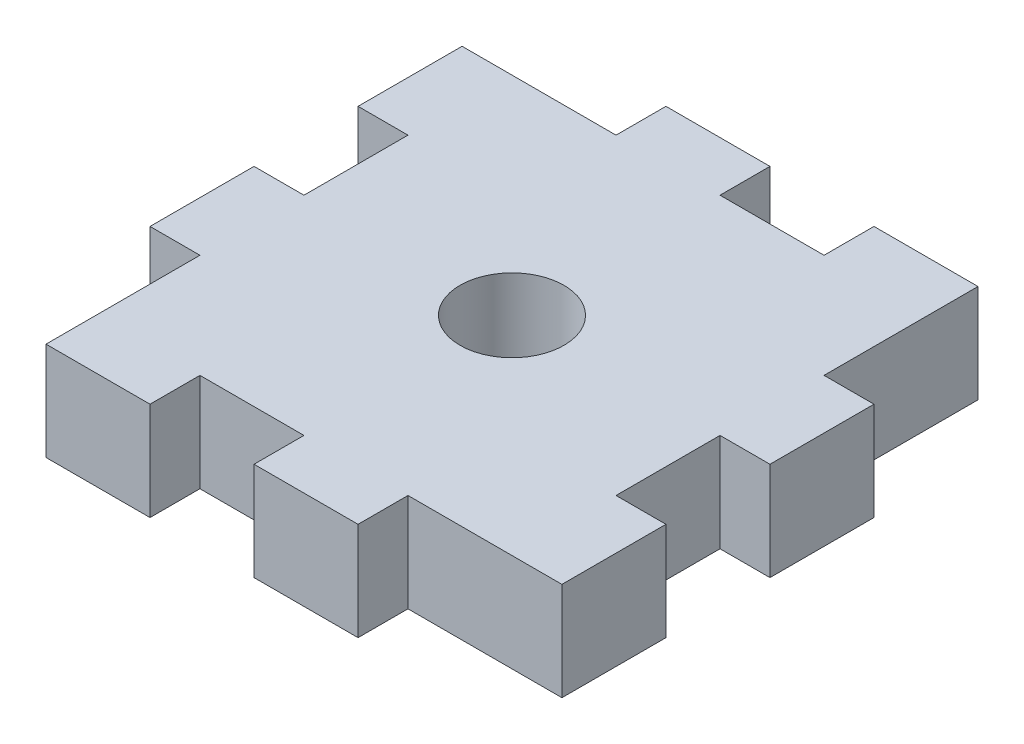
from build123d import *

# Parameters (mm, degrees)
SKETCH1_R           = 3.175
BOSS_EXTRUDE1_DEPTH = 5.9944


with BuildPart() as part:
    # Sketch1 → Boss-Extrude1 (new body)
    with BuildSketch(Plane(origin=(0, 0, 0), x_dir=(1, 0, 0), z_dir=(0, 1, 0))):
        Polygon((28.448, 3.048), (19.05, 3.048), (19.05, 0), (12.7, 0), (12.7, 3.048), (6.35, 3.048), (6.35, 0), (0, 0), (0, 9.398), (-3.048, 9.398), (-3.048, 15.748), (0, 15.748), (0, 22.098), (-3.048, 22.098), (-3.048, 28.448), (6.35, 28.448), (6.35, 31.496), (12.7, 31.496), (12.7, 28.448), (19.05, 28.448), (19.05, 31.496), (25.4, 31.496), (25.4, 22.098), (28.448, 22.098), (28.448, 15.748), (25.4, 15.748), (25.4, 9.398), (28.448, 9.398), align=None)
        with Locations((12.7, 15.748)):
            Circle(SKETCH1_R, mode=Mode.SUBTRACT)
    extrude(amount=BOSS_EXTRUDE1_DEPTH)


solid = part.part
